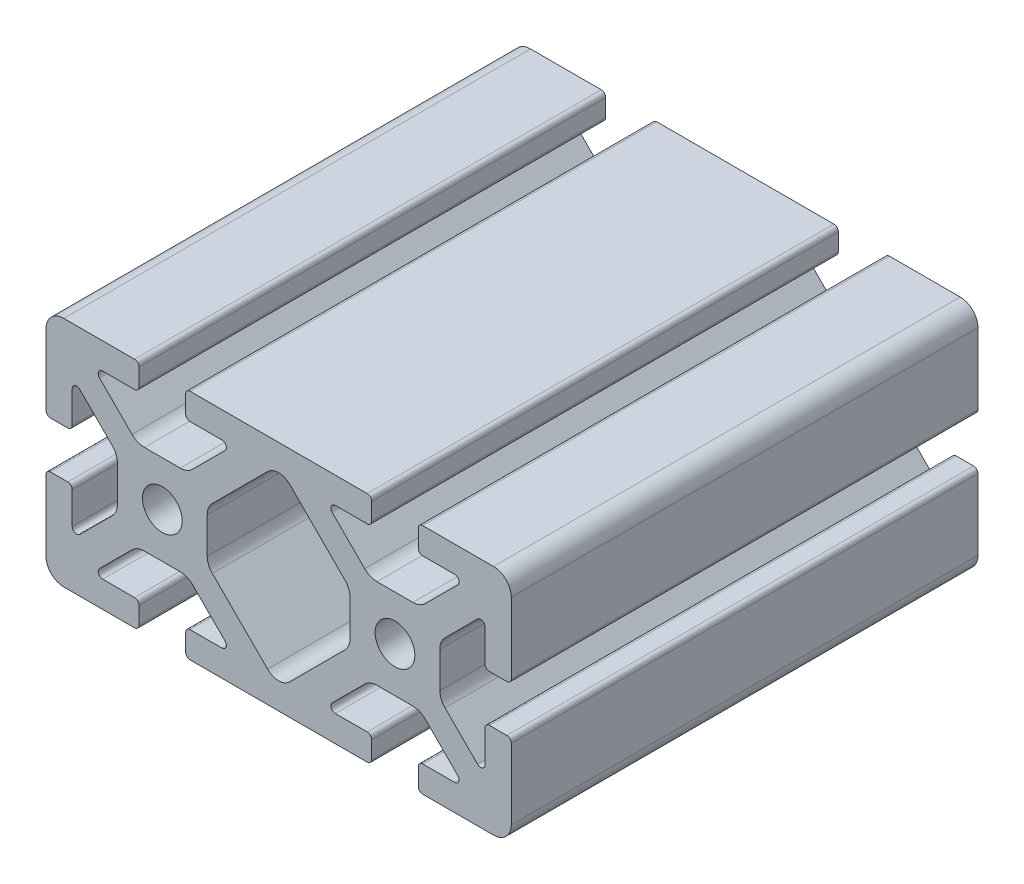
from build123d import *

# Parameters (mm, degrees)
SKETCH1_R               = 3.4036
BOSS_EXTRUDE1_DEPTH     = 152.4
SKETCH2_W               = 224.8
SKETCH2_H               = 39.878
CUT_EXTRUDE1_DEPTH      = 40
CUT_EXTRUDE1_DEPTH_BACK = 40


with BuildPart() as part:
    # Sketch1 → Boss-Extrude1 (new body, symmetric)
    with BuildSketch(Plane.XY):
        with BuildLine():
            Line((-39.878, 16.891), (-39.878, 4.7625))
            ThreePointArc((-39.878, 4.7625), (-39.654815367, 4.223684633), (-39.116, 4.0005))
            Line((-39.116, 4.0005), (-36.1442, 4.0005))
            ThreePointArc((-36.1442, 4.0005), (-35.605384633, 4.223684633), (-35.3822, 4.7625))
            Line((-35.3822, 4.7625), (-35.3822, 10.2235))
            ThreePointArc((-35.3822, 10.2235), (-34.911804775, 10.927496204), (-34.081384633, 10.762315367))
            Line((-34.081384633, 10.762315367), (-28.513059555, 5.19399029))
            ThreePointArc((-28.513059555, 5.19399029), (-27.863348265, 4.221628629), (-27.6352, 3.074649845))
            Line((-27.6352, 3.074649845), (-27.6352, -3.074649845))
            ThreePointArc((-27.6352, -3.074649845), (-27.863348265, -4.221628629), (-28.513059555, -5.19399029))
            Line((-28.513059555, -5.19399029), (-34.081384633, -10.762315367))
            ThreePointArc((-34.081384633, -10.762315367), (-34.911804775, -10.927496204), (-35.3822, -10.2235))
            Line((-35.3822, -10.2235), (-35.3822, -4.7625))
            ThreePointArc((-35.3822, -4.7625), (-35.605384633, -4.223684633), (-36.1442, -4.0005))
            Line((-36.1442, -4.0005), (-39.116, -4.0005))
            ThreePointArc((-39.116, -4.0005), (-39.654815367, -4.223684633), (-39.878, -4.7625))
            Line((-39.878, -4.7625), (-39.878, -16.891))
            ThreePointArc((-39.878, -16.891), (-38.985261469, -19.046261469), (-36.83, -19.939))
            Line((-36.83, -19.939), (-24.7015, -19.939))
            ThreePointArc((-24.7015, -19.939), (-24.162684633, -19.715815367), (-23.9395, -19.177))
            Line((-23.9395, -19.177), (-23.9395, -16.2052))
            ThreePointArc((-23.9395, -16.2052), (-24.162684633, -15.666384633), (-24.7015, -15.4432))
            Line((-24.7015, -15.4432), (-30.1625, -15.4432))
            ThreePointArc((-30.1625, -15.4432), (-30.866496204, -14.972804775), (-30.701315367, -14.142384633))
            Line((-30.701315367, -14.142384633), (-25.13299029, -8.574059555))
            ThreePointArc((-25.13299029, -8.574059555), (-24.160628629, -7.924348265), (-23.013649845, -7.6962))
            Line((-23.013649845, -7.6962), (-16.864350155, -7.6962))
            ThreePointArc((-16.864350155, -7.6962), (-15.717371371, -7.924348265), (-14.74500971, -8.574059555))
            Line((-14.74500971, -8.574059555), (-9.176684633, -14.142384633))
            ThreePointArc((-9.176684633, -14.142384633), (-9.011503796, -14.972804775), (-9.7155, -15.4432))
            Line((-9.7155, -15.4432), (-15.1765, -15.4432))
            ThreePointArc((-15.1765, -15.4432), (-15.715315367, -15.666384633), (-15.9385, -16.2052))
            Line((-15.9385, -16.2052), (-15.9385, -19.177))
            ThreePointArc((-15.9385, -19.177), (-15.715315367, -19.715815367), (-15.1765, -19.939))
            Line((-15.1765, -19.939), (15.1765, -19.939))
            ThreePointArc((15.1765, -19.939), (15.715315367, -19.715815367), (15.9385, -19.177))
            Line((15.9385, -19.177), (15.9385, -16.2052))
            ThreePointArc((15.9385, -16.2052), (15.715315367, -15.666384633), (15.1765, -15.4432))
            Line((15.1765, -15.4432), (9.7155, -15.4432))
            ThreePointArc((9.7155, -15.4432), (9.011503796, -14.972804775), (9.176684633, -14.142384633))
            Line((9.176684633, -14.142384633), (14.74500971, -8.574059555))
            ThreePointArc((14.74500971, -8.574059555), (15.717371371, -7.924348265), (16.864350155, -7.6962))
            Line((16.864350155, -7.6962), (23.013649845, -7.6962))
            ThreePointArc((23.013649845, -7.6962), (24.160628629, -7.924348265), (25.13299029, -8.574059555))
            Line((25.13299029, -8.574059555), (30.701315367, -14.142384633))
            ThreePointArc((30.701315367, -14.142384633), (30.866496204, -14.972804775), (30.1625, -15.4432))
            Line((30.1625, -15.4432), (24.7015, -15.4432))
            ThreePointArc((24.7015, -15.4432), (24.162684633, -15.666384633), (23.9395, -16.2052))
            Line((23.9395, -16.2052), (23.9395, -19.177))
            ThreePointArc((23.9395, -19.177), (24.162684633, -19.715815367), (24.7015, -19.939))
            Line((24.7015, -19.939), (36.83, -19.939))
            ThreePointArc((36.83, -19.939), (38.985261469, -19.046261469), (39.878, -16.891))
            Line((39.878, -16.891), (39.878, -4.7625))
            ThreePointArc((39.878, -4.7625), (39.654815367, -4.223684633), (39.116, -4.0005))
            Line((39.116, -4.0005), (36.1442, -4.0005))
            ThreePointArc((36.1442, -4.0005), (35.605384633, -4.223684633), (35.3822, -4.7625))
            Line((35.3822, -4.7625), (35.3822, -10.2235))
            ThreePointArc((35.3822, -10.2235), (34.911804775, -10.927496204), (34.081384633, -10.762315367))
            Line((34.081384633, -10.762315367), (28.513059555, -5.19399029))
            ThreePointArc((28.513059555, -5.19399029), (27.863348265, -4.221628629), (27.6352, -3.074649845))
            Line((27.6352, -3.074649845), (27.6352, 3.074649845))
            ThreePointArc((27.6352, 3.074649845), (27.863348265, 4.221628629), (28.513059555, 5.19399029))
            Line((28.513059555, 5.19399029), (34.081384633, 10.762315367))
            ThreePointArc((34.081384633, 10.762315367), (34.911804775, 10.927496204), (35.3822, 10.2235))
            Line((35.3822, 10.2235), (35.3822, 4.7625))
            ThreePointArc((35.3822, 4.7625), (35.605384633, 4.223684633), (36.1442, 4.0005))
            Line((36.1442, 4.0005), (39.116, 4.0005))
            ThreePointArc((39.116, 4.0005), (39.654815367, 4.223684633), (39.878, 4.7625))
            Line((39.878, 4.7625), (39.878, 16.891))
            ThreePointArc((39.878, 16.891), (38.985261469, 19.046261469), (36.83, 19.939))
            Line((36.83, 19.939), (24.7015, 19.939))
            ThreePointArc((24.7015, 19.939), (24.162684633, 19.715815367), (23.9395, 19.177))
            Line((23.9395, 19.177), (23.9395, 16.2052))
            ThreePointArc((23.9395, 16.2052), (24.162684633, 15.666384633), (24.7015, 15.4432))
            Line((24.7015, 15.4432), (30.1625, 15.4432))
            ThreePointArc((30.1625, 15.4432), (30.866496204, 14.972804775), (30.701315367, 14.142384633))
            Line((30.701315367, 14.142384633), (25.13299029, 8.574059555))
            ThreePointArc((25.13299029, 8.574059555), (24.160628629, 7.924348265), (23.013649845, 7.6962))
            Line((23.013649845, 7.6962), (16.864350155, 7.6962))
            ThreePointArc((16.864350155, 7.6962), (15.717371371, 7.924348265), (14.74500971, 8.574059555))
            Line((14.74500971, 8.574059555), (9.176684633, 14.142384633))
            ThreePointArc((9.176684633, 14.142384633), (9.011503796, 14.972804775), (9.7155, 15.4432))
            Line((9.7155, 15.4432), (15.1765, 15.4432))
            ThreePointArc((15.1765, 15.4432), (15.715315367, 15.666384633), (15.9385, 16.2052))
            Line((15.9385, 16.2052), (15.9385, 19.177))
            ThreePointArc((15.9385, 19.177), (15.715315367, 19.715815367), (15.1765, 19.939))
            Line((15.1765, 19.939), (-15.1765, 19.939))
            ThreePointArc((-15.1765, 19.939), (-15.715315367, 19.715815367), (-15.9385, 19.177))
            Line((-15.9385, 19.177), (-15.9385, 16.2052))
            ThreePointArc((-15.9385, 16.2052), (-15.715315367, 15.666384633), (-15.1765, 15.4432))
            Line((-15.1765, 15.4432), (-9.7155, 15.4432))
            ThreePointArc((-9.7155, 15.4432), (-9.011503796, 14.972804775), (-9.176684633, 14.142384633))
            Line((-9.176684633, 14.142384633), (-14.74500971, 8.574059555))
            ThreePointArc((-14.74500971, 8.574059555), (-15.717371371, 7.924348265), (-16.864350155, 7.6962))
            Line((-16.864350155, 7.6962), (-23.013649845, 7.6962))
            ThreePointArc((-23.013649845, 7.6962), (-24.160628629, 7.924348265), (-25.13299029, 8.574059555))
            Line((-25.13299029, 8.574059555), (-30.701315367, 14.142384633))
            ThreePointArc((-30.701315367, 14.142384633), (-30.866496204, 14.972804775), (-30.1625, 15.4432))
            Line((-30.1625, 15.4432), (-24.7015, 15.4432))
            ThreePointArc((-24.7015, 15.4432), (-24.162684633, 15.666384633), (-23.9395, 16.2052))
            Line((-23.9395, 16.2052), (-23.9395, 19.177))
            ThreePointArc((-23.9395, 19.177), (-24.162684633, 19.715815367), (-24.7015, 19.939))
            Line((-24.7015, 19.939), (-36.83, 19.939))
            ThreePointArc((-36.83, 19.939), (-38.985261469, 19.046261469), (-39.878, 16.891))
        make_face()
        with Locations((-19.939, 0)):
            Circle(SKETCH1_R, mode=Mode.SUBTRACT)
        with Locations((19.939, 0)):
            Circle(SKETCH1_R, mode=Mode.SUBTRACT)
        with BuildLine():
            Line((-12.2428, 3.074649845), (-12.2428, -3.074649845))
            ThreePointArc((-12.2428, -3.074649845), (-12.014651735, -4.221628629), (-11.364940445, -5.19399029))
            Line((-11.364940445, -5.19399029), (-1.904671503, -14.654259232))
            ThreePointArc((-1.904671503, -14.654259232), (0, -15.4432), (1.904671503, -14.654259232))
            Line((1.904671503, -14.654259232), (11.364940445, -5.19399029))
            ThreePointArc((11.364940445, -5.19399029), (12.014651735, -4.221628629), (12.2428, -3.074649845))
            Line((12.2428, -3.074649845), (12.2428, 3.074649845))
            ThreePointArc((12.2428, 3.074649845), (12.014651735, 4.221628629), (11.364940445, 5.19399029))
            Line((11.364940445, 5.19399029), (1.904671503, 14.654259232))
            ThreePointArc((1.904671503, 14.654259232), (0, 15.4432), (-1.904671503, 14.654259232))
            Line((-1.904671503, 14.654259232), (-11.364940445, 5.19399029))
            ThreePointArc((-11.364940445, 5.19399029), (-12.014651735, 4.221628629), (-12.2428, 3.074649845))
        make_face(mode=Mode.SUBTRACT)
    extrude(amount=BOSS_EXTRUDE1_DEPTH, both=True)

    # Sketch2 → Cut-Extrude1 (cut, two sides)
    with BuildSketch(Plane(origin=(0, 0, 0), x_dir=(0, 0, -1), z_dir=(1, 0, 0))) as cut_extrude1_sk:
        with Locations((40, 0)):
            Rectangle(SKETCH2_W, SKETCH2_H)
    extrude(amount=CUT_EXTRUDE1_DEPTH, mode=Mode.SUBTRACT)
    extrude(cut_extrude1_sk.sketch, amount=-CUT_EXTRUDE1_DEPTH_BACK, mode=Mode.SUBTRACT)


solid = part.part
